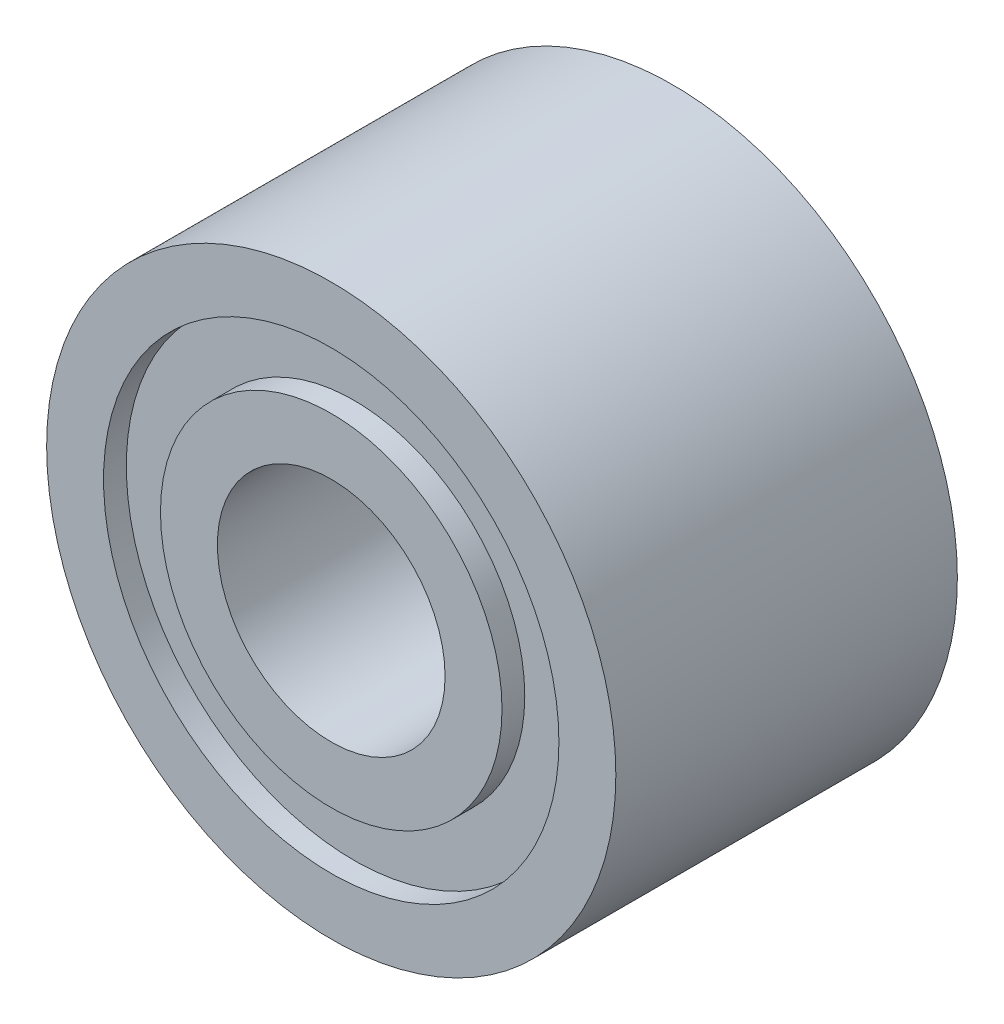
from build123d import *


with BuildPart() as part:
    # Sketch2 → Revolve1 (revolve)
    with BuildSketch(Plane(origin=(0, 0, 0), x_dir=(0, 0, -1), z_dir=(1, 0, 0))):
        Polygon((1.10919003, 2.5), (4.10919003, 2.5), (4.10919003, 2), (3.90919003, 2), (3.90919003, 1.5), (4.10919003, 1.5), (4.10919003, 1), (1.10919003, 1), (1.10919003, 1.5), (1.30919003, 1.5), (1.30919003, 2), (1.10919003, 2), align=None)
    revolve(axis=Axis((0, 0, 0), (0, 0, -1)))


solid = part.part
